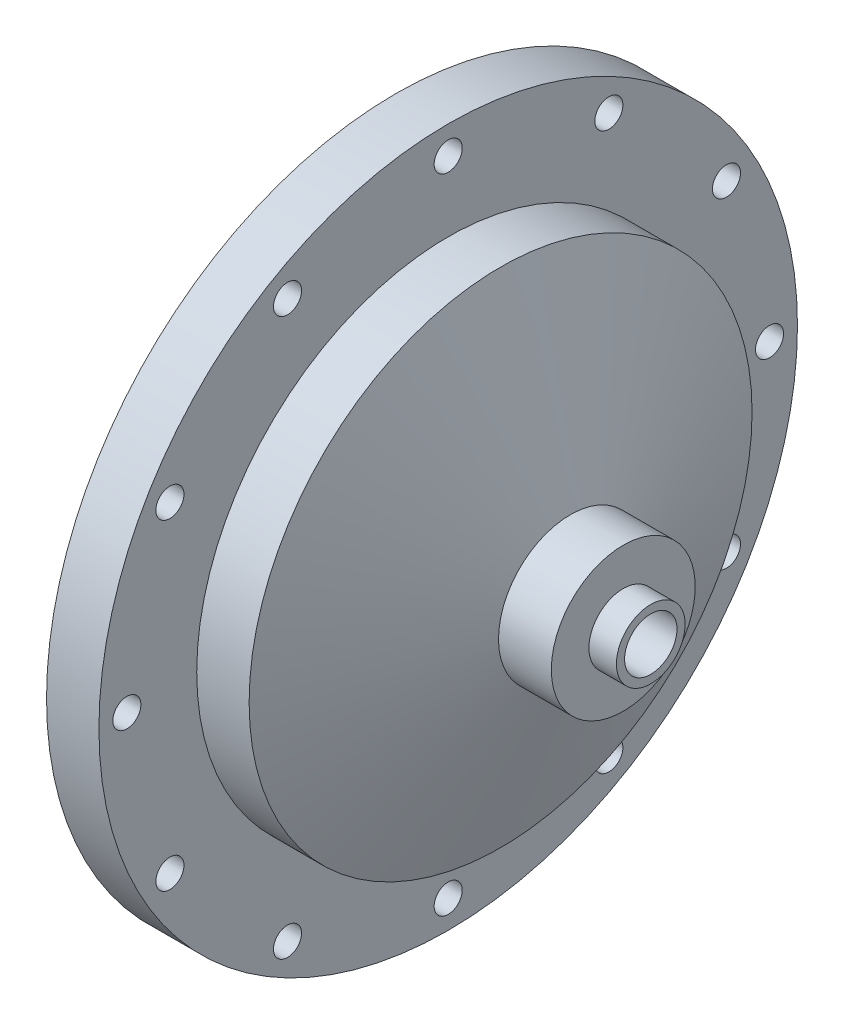
from build123d import *

# Parameters (mm, degrees)
SKETCH3_R                       = 4.7625
OXIDIZER_INLET_HOLE_DEPTH       = 102.060803604
FLANGE_HOLES_D                  = 5.1054
DOWEL_HOLES_D                   = 4.7625
DOWEL_HOLES_DEPTH               = 6.35
DOWEL_HOLES_TIP                 = 1.430799349
SKETCH12_R                      = 38.1
IMPINGING_PLATE_FLAT_CUT_DEPTH  = 3.81
SKETCH14_R                      = 38.1
SKETCH15_R                      = 38.1
SKETCH16_R                      = 28.575
SKETCH17_R                      = 4.7625
SKETCH21_R                      = 28.575
CUT_EXTRUDE1_DEPTH              = 9.525
INTERNAL_FILLET_R               = 3.175
EXTENDED_8_BC_COUNT             = 8
CHAMFER_FOR_IMPINGING_EDGE_SIZE = 0.127


with BuildPart() as part:
    # Sketch2 → Main Structure (revolve)
    with BuildSketch(Plane.XY, mode=Mode.PRIVATE) as main_structure_sk:
        Polygon((0, 0), (0, 63.5), (9.525, 63.5), (9.525, 45.72), (19.05, 45.72), (31.75, 13.081), (41.355, 13.081), (41.355, 6.2484), (46.355, 6.2484), (46.355, 0), align=None)
    revolve(main_structure_sk.sketch.rotate(Axis((0, 0, 0), (1, 0, 0)), 90), axis=Axis((0, 0, 0), (1, 0, 0)))

    # Sketch3 → Oxidizer Inlet Hole (cut, through all)
    with BuildSketch(Plane(origin=(46.355, 0, 0), x_dir=(0, 0, -1), z_dir=(1, 0, 0))):
        Circle(SKETCH3_R)
    extrude(amount=-OXIDIZER_INLET_HOLE_DEPTH, mode=Mode.SUBTRACT)

    # Flange Holes (through all)
    with Locations(Plane.ZY):
        with Locations((0, -58.42), (-29.21, -50.593204089), (-50.593204089, -29.21), (-58.42, 0), (-50.593204089, 29.21), (-29.21, 50.593204089), (0, 58.42), (29.21, 50.593204089), (50.593204089, 29.21), (58.42, 0), (50.593204089, -29.21), (29.21, -50.593204089)):
            Hole(FLANGE_HOLES_D / 2)

    # Dowel Holes
    with Locations(Plane.ZY):
        with Locations((56.429386772, -15.120208615), (-56.429386772, 15.120208615)):
            Hole(DOWEL_HOLES_D / 2, depth=DOWEL_HOLES_DEPTH)
            with Locations((0, 0, -(DOWEL_HOLES_DEPTH + DOWEL_HOLES_TIP / 2))):  # 118° drill point
                Cone(0, DOWEL_HOLES_D / 2, DOWEL_HOLES_TIP, mode=Mode.SUBTRACT)

    # Sketch12 → Impinging Plate Flat Cut (cut)
    with BuildSketch(Plane.ZY):
        Circle(SKETCH12_R)
    extrude(amount=-IMPINGING_PLATE_FLAT_CUT_DEPTH, mode=Mode.SUBTRACT)

    # Sketch14 → Impinging Plate Taper Cut section 0
    with BuildSketch(Plane.ZY.offset(-3.81)):
        Circle(SKETCH14_R)
    # Sketch15 → Impinging Plate Taper Cut section 1
    with BuildSketch(Plane.ZY.offset(-6.35)):
        Circle(SKETCH15_R)
    loft(mode=Mode.SUBTRACT)

    # Sketch16 → Internal Flow Path Loft Cut section 0
    with BuildSketch(Plane.ZY.offset(-15.875)):
        Circle(SKETCH16_R)
    # Sketch17 → Internal Flow Path Loft Cut section 1
    with BuildSketch(Plane.ZY.offset(-31.115)):
        Circle(SKETCH17_R)
    loft(mode=Mode.SUBTRACT)

    # Sketch21 → Cut-Extrude1 (cut)
    with BuildSketch(Plane.ZY.offset(-6.35)):
        Circle(SKETCH21_R)
    extrude(amount=-CUT_EXTRUDE1_DEPTH, mode=Mode.SUBTRACT)

    # Internal Fillet
    internal_fillet_edges = [part.edges().sort_by_distance(p)[0] for p in [
        (31.115, 4.7625, 0),
    ]]
    fillet(internal_fillet_edges, radius=INTERNAL_FILLET_R)

    # Sketch20 → 4-40 Tapped Holes (revolve, cut)
    with BuildSketch(Plane(origin=(6.35, 0, 33.3375), x_dir=(0, 0, 1), z_dir=(0, 1, 0))):
        Polygon((0, 0), (0, 13.887152758), (1.1303, 13.208), (1.1303, 0), align=None)
    f_4_40_tapped_holes = revolve(axis=Axis((0, 0, 33.3375), (1, 0, 0)), mode=Mode.SUBTRACT)

    # Extended 8 BC: 4-40 Tapped Holes ×8 about axis
    extended_8_bc_axis = Axis((0, 0, 0), (1, 0, 0))
    for i in range(1, EXTENDED_8_BC_COUNT):
        add(f_4_40_tapped_holes.rotate(extended_8_bc_axis, i * 360 / EXTENDED_8_BC_COUNT), mode=Mode.SUBTRACT)

    # Chamfer for Impinging Edge
    chamfer_for_impinging_edge_edges = [part.edges().sort_by_distance(p)[0] for p in [
        (6.35, 0, -38.1),
    ]]
    chamfer(chamfer_for_impinging_edge_edges, length=CHAMFER_FOR_IMPINGING_EDGE_SIZE)


solid = part.part
